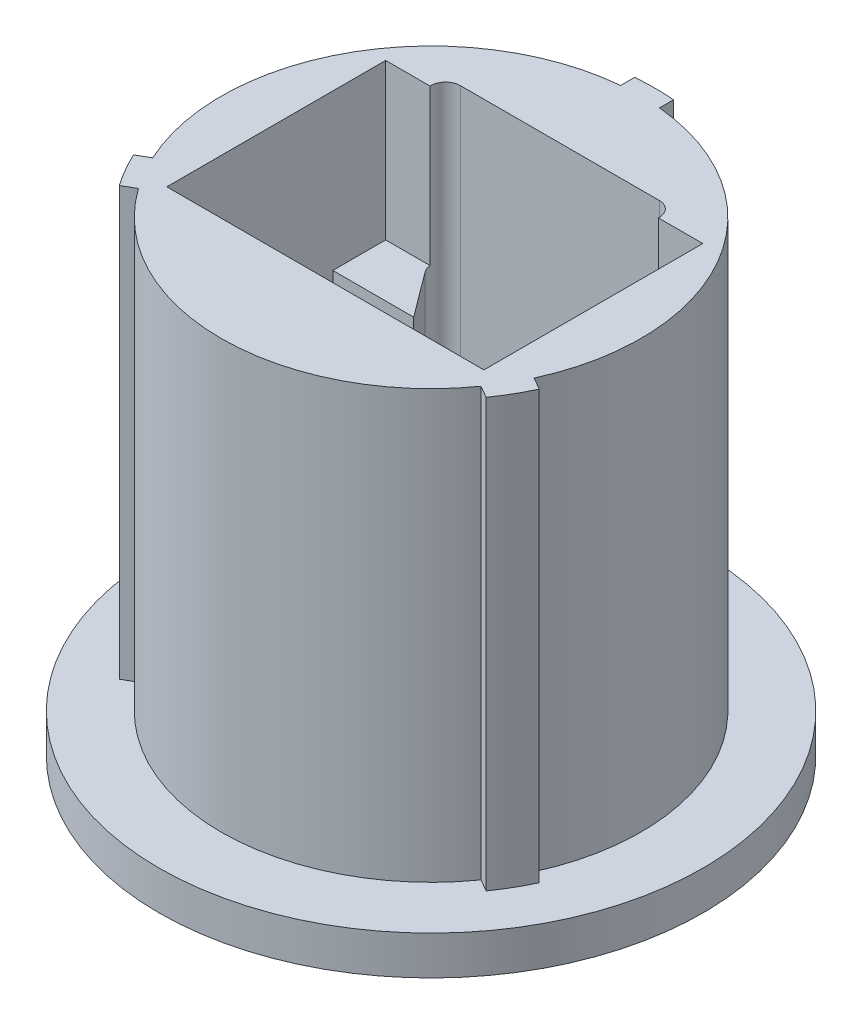
from build123d import *

# Parameters (mm, degrees)
BOSS_EXTRUDE1_DEPTH = 19.05
CUT_EXTRUDE1_DEPTH  = 23.803574111
CUT_EXTRUDE2_DEPTH  = 18.25625
SKETCH6_W           = 0.608326788
SKETCH6_H           = 1.5875
SKETCH8_W           = 2.576826788
SKETCH8_H           = 1.5875
SKETCH9_W           = 12.954
SKETCH9_H           = 5.08
SKETCH9_H_2         = 2.159
CUT_EXTRUDE3_DEPTH  = 6.35


with BuildPart() as part:
    # Sketch1 → Boss-Extrude1 (new body)
    with BuildSketch(Plane(origin=(0, 0, 0), x_dir=(1, 0, 0), z_dir=(0, 1, 0))):
        with BuildLine():
            Line((-0.79375, 9.109483901), (-0.79375, 8.535673212))
            ThreePointArc((-0.79375, 8.535673212), (-7.424002774, 4.28625), (-7.78898484, -3.580428942))
            Line((-7.78898484, -3.580428942), (-8.285919473, -3.867334286))
            ThreePointArc((-8.285919473, -3.867334286), (-7.918936292, -4.572), (-7.492169473, -5.242149615))
            Line((-7.492169473, -5.242149615), (-6.99523484, -4.95524427))
            ThreePointArc((-6.99523484, -4.95524427), (0, -8.5725), (6.99523484, -4.95524427))
            Line((6.99523484, -4.95524427), (7.492169473, -5.242149615))
            ThreePointArc((7.492169473, -5.242149615), (7.918936292, -4.572), (8.285919473, -3.867334286))
            Line((8.285919473, -3.867334286), (7.78898484, -3.580428942))
            ThreePointArc((7.78898484, -3.580428942), (7.424002774, 4.28625), (0.79375, 8.535673212))
            Line((0.79375, 8.535673212), (0.79375, 9.109483901))
            ThreePointArc((0.79375, 9.109483901), (0, 9.144), (-0.79375, 9.109483901))
        make_face()
    extrude(amount=BOSS_EXTRUDE1_DEPTH)

    # Sketch2 → Cut-Extrude1 (cut, through all)
    with BuildSketch(Plane(origin=(0, 19.05, 0), x_dir=(1, 0, 0), z_dir=(0, 1, 0))):
        with BuildLine():
            Line((-4.543615348, 4.303093955), (-3.175, 2.4638))
            Line((-3.175, 2.4638), (3.175, 2.4638))
            Line((3.175, 2.4638), (4.543615348, 4.303093955))
            ThreePointArc((4.543615348, 4.303093955), (4.598203733, 4.928342625), (4.064, 5.2578))
            Line((4.064, 5.2578), (-4.064, 5.2578))
            ThreePointArc((-4.064, 5.2578), (-4.598203733, 4.928342625), (-4.543615348, 4.303093955))
        make_face()
    extrude(amount=-CUT_EXTRUDE1_DEPTH, mode=Mode.SUBTRACT)

    # Sketch2_4 → Cut-Extrude2 (cut)
    with BuildSketch(Plane(origin=(0, 19.05, 0), x_dir=(1, 0, 0), z_dir=(0, 1, 0))):
        Polygon((3.175, 2.4638), (-3.175, 2.4638), (-6.477, 2.4638), (-6.477, 0.762), (6.477, 0.762), (6.477, 2.4638), align=None)
    extrude(amount=-CUT_EXTRUDE2_DEPTH, mode=Mode.SUBTRACT)

    # Sketch6 → Cut-Revolve2 (revolve, cut)
    with BuildSketch(Plane(origin=(0, 0, 0), x_dir=(0, 0, -1), z_dir=(1, 0, 0))):
        with Locations((8.839836606, 0.79375)):
            Rectangle(SKETCH6_W, SKETCH6_H)
    revolve(axis=Axis((0, 19.730213777, 0), (0, -1, 0)), mode=Mode.SUBTRACT)

    # Sketch8 → Revolve2 (revolve)
    with BuildSketch(Plane(origin=(0, 0, 0), x_dir=(0, 0, -1), z_dir=(1, 0, 0))):
        with Locations((9.824086606, 0.79375)):
            Rectangle(SKETCH8_W, SKETCH8_H)
    revolve(axis=Axis((0, 4.48386458, 0), (0, -1, 0)))

    # Sketch9 → Cut-Extrude3 (cut)
    with BuildSketch(Plane(origin=(0, 19.05, 0), x_dir=(1, 0, 0), z_dir=(0, 1, 0))):
        with Locations((0, -1.778)):
            Rectangle(SKETCH9_W, SKETCH9_H)
        with Locations((0, 3.5433)):
            Rectangle(SKETCH9_W, SKETCH9_H_2)
    extrude(amount=-CUT_EXTRUDE3_DEPTH, mode=Mode.SUBTRACT)


solid = part.part
